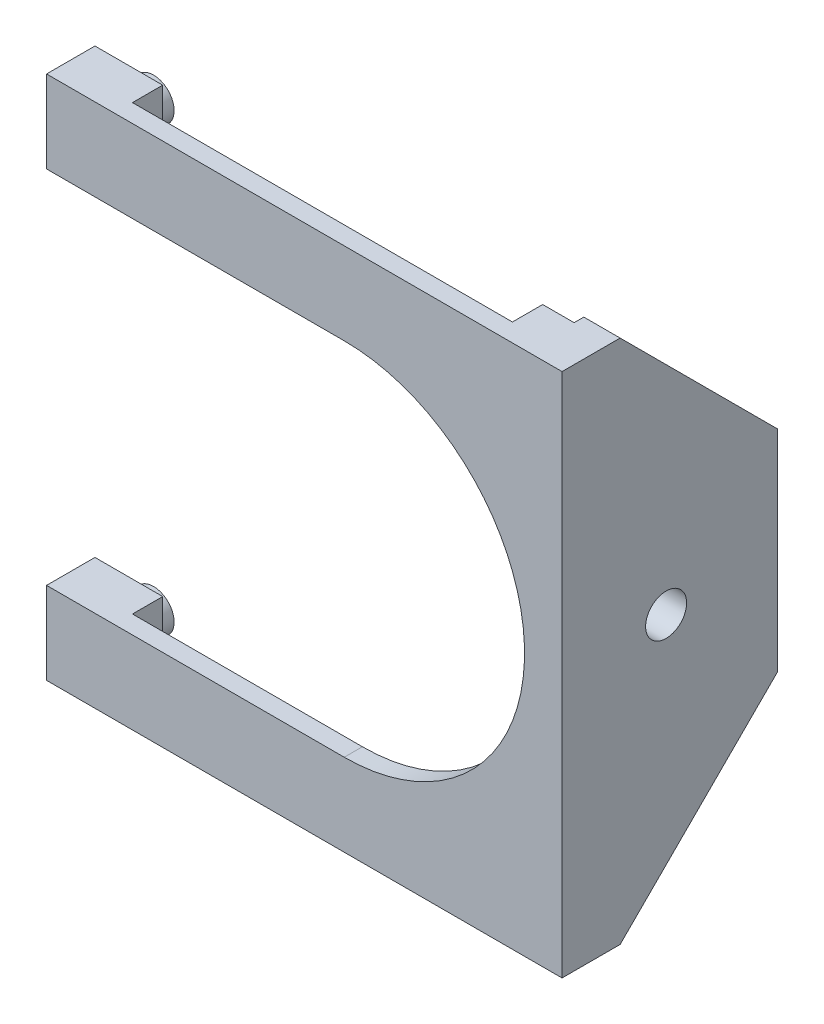
from build123d import *

# Parameters (mm, degrees)
BOSS_EXTRUDE1_DEPTH       = 22.606
CUT_EXTRUDE1_DEPTH        = 56.118
F_8_CLEARANCE_HOLE1_D     = 4.3053
F_8_CLEARANCE_HOLE1_DEPTH = 3.81
CHAMFER1_SIZE             = 16.51


with BuildPart() as part:
    # Sketch1 w/mock PCB → Boss-Extrude1 (new body)
    with BuildSketch(Plane.XY):
        with BuildLine():
            Line((-19.05, 18.923), (-50.292, 18.923))
            Line((-50.292, 18.923), (-50.292, 27.559))
            Line((-50.292, 27.559), (3.81, 27.559))
            Line((3.81, 27.559), (3.81, -27.559))
            Line((3.81, -27.559), (-50.292, -27.559))
            Line((-50.292, -27.559), (-50.292, -18.923))
            Line((-50.292, -18.923), (-19.05, -18.923))
            ThreePointArc((-19.05, -18.923), (-0.127, 0), (-19.05, 18.923))
        make_face()
    extrude(amount=-BOSS_EXTRUDE1_DEPTH)

    # Sketch1 → Cut-Extrude1 (cut, through all)
    with BuildSketch(Plane.XZ.offset(27.559)):
        Polygon((-3.302, -5.08), (-3.302, -1.905), (-43.18, -1.905), (-43.18, -5.08), (-50.292, -5.08), (-50.292, -22.606), (0, -22.606), (0, -5.08), align=None)
    extrude(amount=-CUT_EXTRUDE1_DEPTH, mode=Mode.SUBTRACT)

    # #8 Clearance Hole1
    with Locations(Plane(origin=(3.81, 0, 0), x_dir=(0, 0, -1), z_dir=(1, 0, 0))):
        with Locations((10.922, 0)):
            Hole(F_8_CLEARANCE_HOLE1_D / 2, depth=F_8_CLEARANCE_HOLE1_DEPTH)

    # Sketch8 → Revolve1 (revolve)
    with BuildSketch(Plane(origin=(0, 23.241, 0), x_dir=(1, 0, 0), z_dir=(0, 1, 0))):
        with BuildLine():
            Line((-46.736, 8.0518), (-46.736, 5.08))
            Line((-46.736, 5.08), (-44.577, 5.08))
            Line((-44.577, 5.08), (-44.577, 7.673501516))
            ThreePointArc((-44.577, 7.673501516), (-45.640053977, 7.95651041), (-46.736, 8.0518))
        make_face()
    revolve1 = revolve(axis=Axis((-46.736, 23.241, -5.08), (0, 0, 1)))

    # Mirror1: Revolve1 across plane
    add(revolve1.mirror(Plane.ZX))

    # Chamfer1
    chamfer1_edges = [part.edges().sort_by_distance(p)[0] for p in [
        (1.905, -27.559, -22.606),
        (1.905, 27.559, -22.606),
    ]]
    chamfer(chamfer1_edges, length=CHAMFER1_SIZE)


solid = part.part
